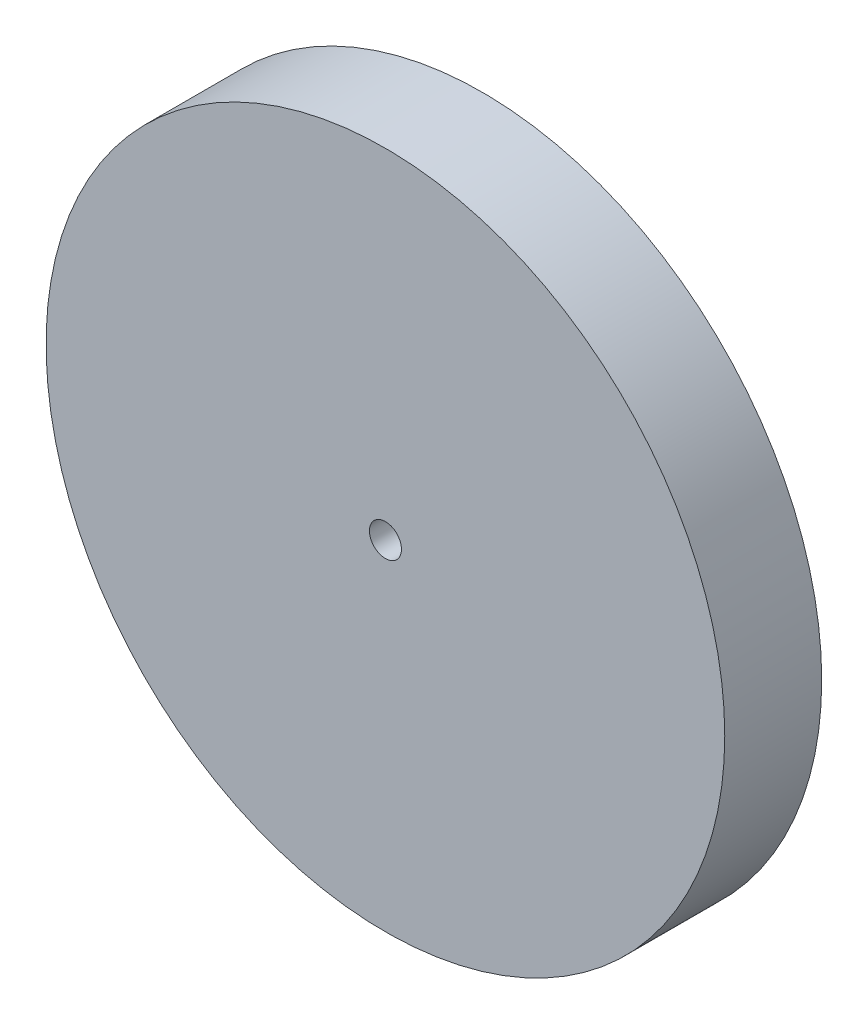
from build123d import *

# Parameters (mm, degrees)
SKETCH1_R           = 35
BOSS_EXTRUDE1_DEPTH = 10
SKETCH2_R           = 1.5
BOSS_EXTRUDE2_DEPTH = 5
SKETCH3_R           = 1.65
CUT_EXTRUDE1_DEPTH  = 5


with BuildPart() as part:
    # Sketch1 → Boss-Extrude1 (new body)
    with BuildSketch(Plane.XY):
        Circle(SKETCH1_R)
    extrude(amount=BOSS_EXTRUDE1_DEPTH)

    # Sketch2 → Boss-Extrude2 (add)
    with BuildSketch(Plane(origin=(0, 0, 0), x_dir=(-1, 0, 0), z_dir=(0, 0, -1))):
        Circle(SKETCH2_R)
    extrude(amount=BOSS_EXTRUDE2_DEPTH)

    # Sketch3 → Cut-Extrude1 (cut)
    with BuildSketch(Plane.XY.offset(10)):
        Circle(SKETCH3_R)
    extrude(amount=-CUT_EXTRUDE1_DEPTH, mode=Mode.SUBTRACT)


solid = part.part
